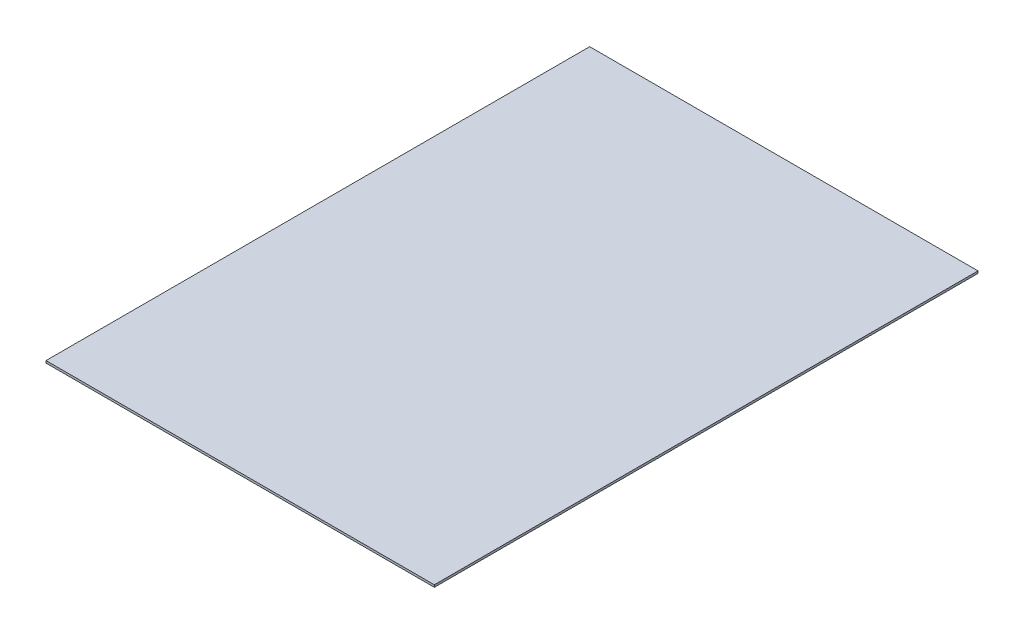
from build123d import *

# Parameters (mm, degrees)
SKETCH_1_W      = 175
SKETCH_1_H      = 245
EXTRUDE_1_DEPTH = 1


with BuildPart() as part:
    # Эскиз1 → Бобышка-Вытянуть1 (new body)
    with BuildSketch(Plane(origin=(0, 0, 0), x_dir=(1, 0, 0), z_dir=(0, 1, 0))):
        Rectangle(SKETCH_1_W, SKETCH_1_H)
    extrude(amount=EXTRUDE_1_DEPTH)


solid = part.part
